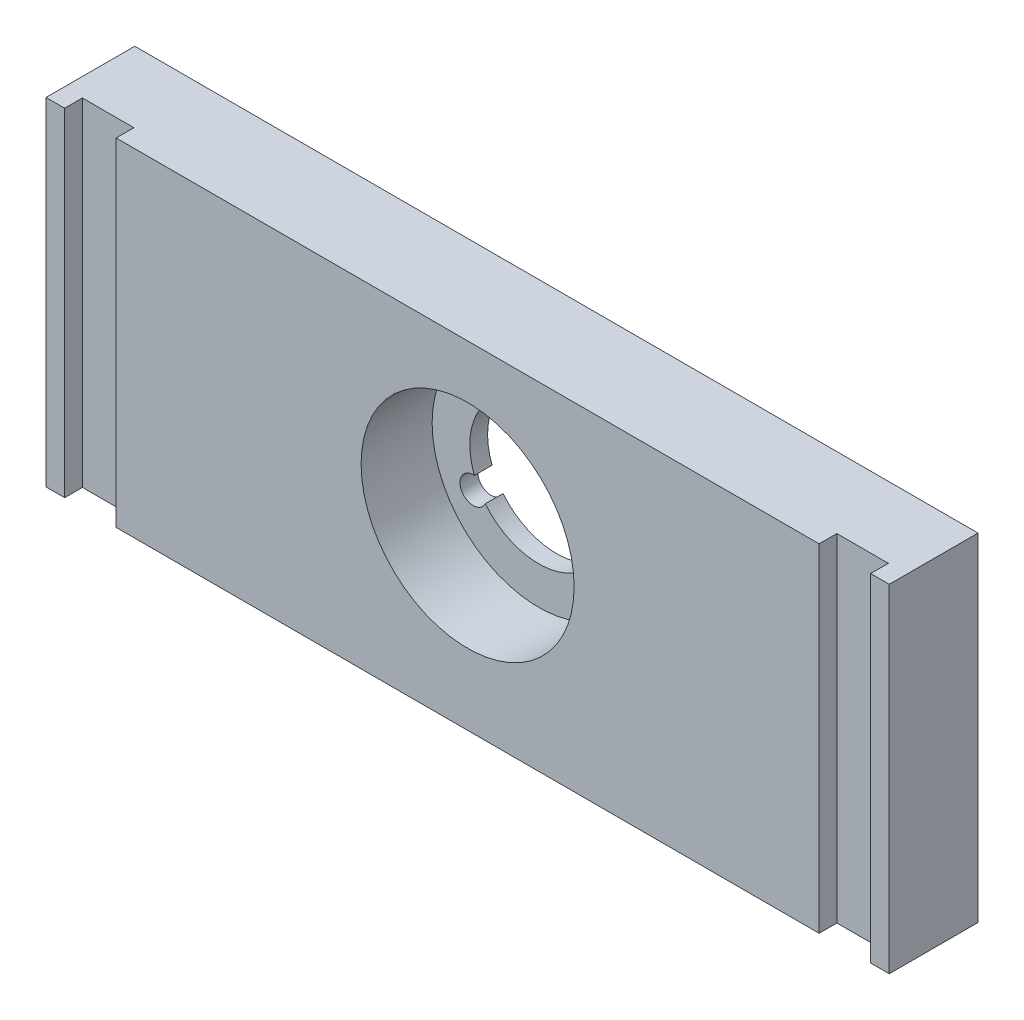
from build123d import *

# Parameters (mm, degrees)
ESQUISSE1_W      = 95
ESQUISSE1_H      = 38
EXTRUSION1_DEPTH = 10
ESQUISSE3_R      = 12
EXTRUSION3_DEPTH = 8
ESQUISSE4_W      = 5.8
ESQUISSE4_H      = 38
EXTRUSION4_DEPTH = 2


with BuildPart() as part:
    # Esquisse1 → Extrusion1 (new body)
    with BuildSketch(Plane.XY):
        with Locations((50.5, -21)):
            Rectangle(ESQUISSE1_W, ESQUISSE1_H)
        with BuildLine():
            ThreePointArc((49.263573917, -12.349264706), (43.788303121, -16.125), (43.256055836, -22.754591249))
            ThreePointArc((43.256055836, -22.754591249), (41.839745962, -25), (44.492481919, -24.896144045))
            ThreePointArc((44.492481919, -24.896144045), (50.5, -27.75), (56.507518081, -24.896144045))
            ThreePointArc((56.507518081, -24.896144045), (59.160254038, -25), (57.743944164, -22.754591249))
            ThreePointArc((57.743944164, -22.754591249), (57.211696879, -16.125), (51.736426083, -12.349264706))
            ThreePointArc((51.736426083, -12.349264706), (50.5, -10), (49.263573917, -12.349264706))
        make_face(mode=Mode.SUBTRACT)
    extrude(amount=EXTRUSION1_DEPTH)

    # Esquisse3 → Extrusion3 (cut)
    with BuildSketch(Plane.XY.offset(10)):
        with Locations((50.5, -20)):
            Circle(ESQUISSE3_R)
    extrude(amount=-EXTRUSION3_DEPTH, mode=Mode.SUBTRACT)

    # Esquisse4 → Extrusion4 (cut)
    with BuildSketch(Plane.XY.offset(10)):
        with Locations((8, -21)):
            Rectangle(ESQUISSE4_W, ESQUISSE4_H)
        with Locations((93, -21)):
            Rectangle(ESQUISSE4_W, ESQUISSE4_H)
    extrude(amount=-EXTRUSION4_DEPTH, mode=Mode.SUBTRACT)


solid = part.part
